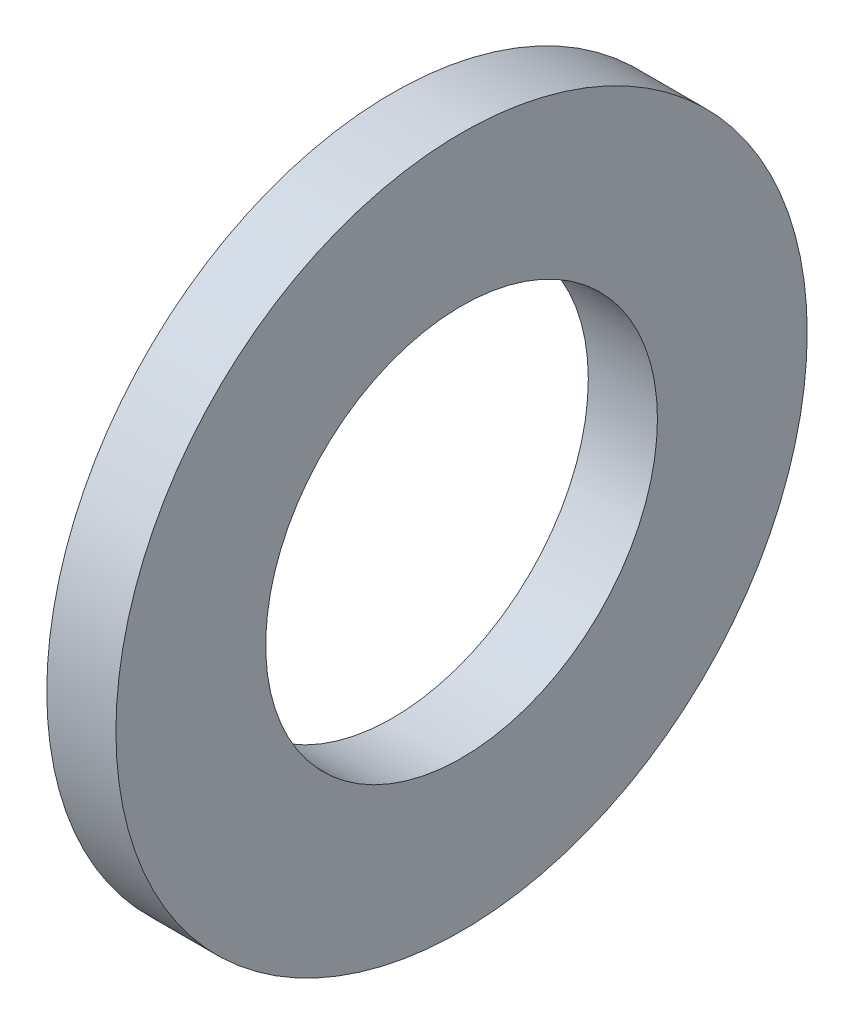
from build123d import *

# Parameters (mm, degrees)
SKETCH1_R           = 15
BOSS_EXTRUDE1_DEPTH = 3
SKETCH2_R           = 8.5
CUT_EXTRUDE1_DEPTH  = 4


with BuildPart() as part:
    # Sketch1 → Boss-Extrude1 (new body)
    with BuildSketch(Plane(origin=(0, 0, 0), x_dir=(0, 0, -1), z_dir=(1, 0, 0))):
        Circle(SKETCH1_R)
    extrude(amount=BOSS_EXTRUDE1_DEPTH)

    # Sketch2 → Cut-Extrude1 (cut, through all)
    with BuildSketch(Plane(origin=(3, 0, 0), x_dir=(0, 0, -1), z_dir=(1, 0, 0))):
        Circle(SKETCH2_R)
    extrude(amount=-CUT_EXTRUDE1_DEPTH, mode=Mode.SUBTRACT)


solid = part.part
